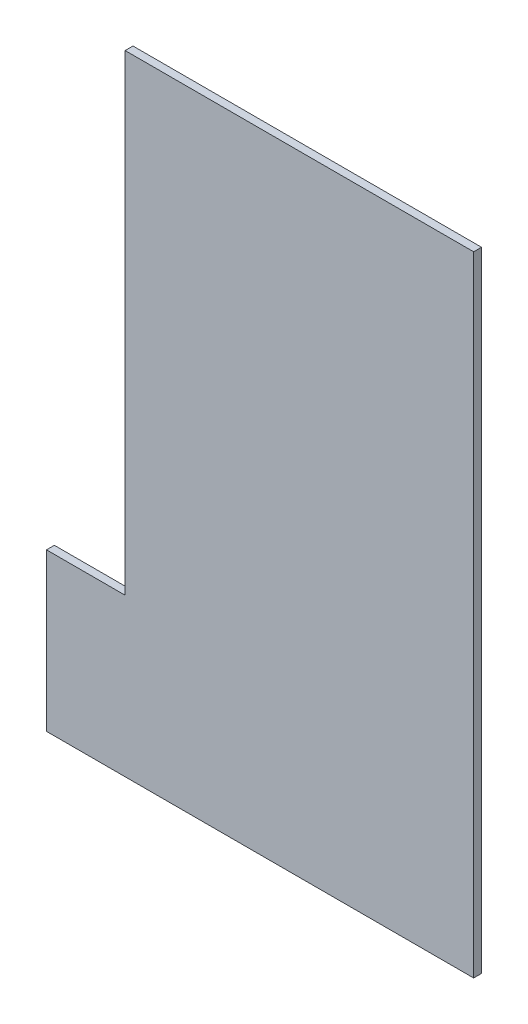
from build123d import *

# Parameters (mm, degrees)
BOSS_EXTRU_1_DEPTH = 3


with BuildPart() as part:
    # Esquisse1 → Boss.-Extru.1 (new body)
    with BuildSketch(Plane.XY):
        Polygon((-62.91023234, 49.317258883), (70.08976766, 49.317258883), (70.08976766, -190.682741117), (-62.91023234, -190.682741117), (-92.91023234, -190.682741117), (-92.91023234, -130.682741117), (-62.91023234, -130.682741117), align=None)
    extrude(amount=BOSS_EXTRU_1_DEPTH)


solid = part.part
